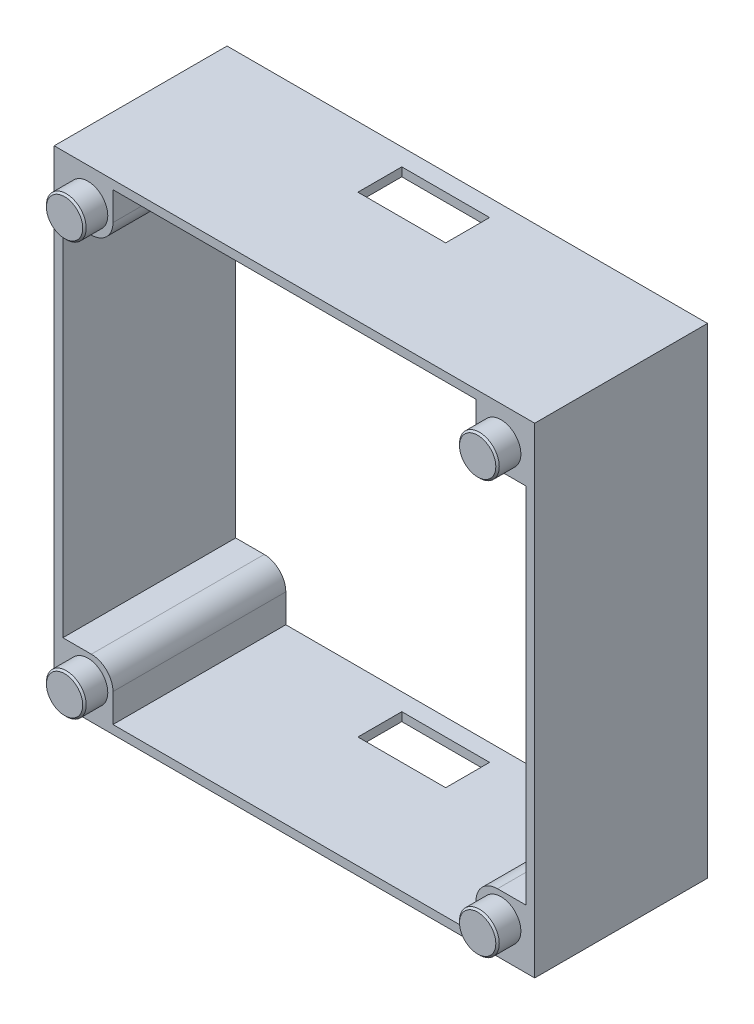
from build123d import *

# Parameters (mm, degrees)
SKICA1_W                 = 5.8
SKICA1_H                 = 5.8
SKICA1_W_2               = 1
SKICA1_H_2               = 42
SKICA1_W_3               = 42
SKICA1_H_3               = 1
P_IDAT_VYSUNUT_M2_DEPTH  = 20
ZAOBLIT1_R               = 2.5
SKICA2_R                 = 2.4
ODEBRAT_VYSUNUT_M1_DEPTH = 1.9
SKICA3_R                 = 2.3
P_IDAT_VYSUNUT_M3_DEPTH  = 2.7
ZKOSEN_1_SIZE            = 0.2
SKICA4_W                 = 10.16
SKICA4_H                 = 5.08
ODEBRAT_VYSUNUT_M2_DEPTH = 68.7


with BuildPart() as part:
    # Skica1 → Přidat vysunutím2 (new body)
    with BuildSketch(Plane.XY):
        Polygon((-27.8, 27.8), (-27.8, 21), (-26.8, 21), (-26.8, 26.8), (-21, 26.8), (-21, 27.8), align=None)
        with Locations((-23.9, 23.9)):
            Rectangle(SKICA1_W, SKICA1_H)
        Polygon((26.8, 21), (27.8, 21), (27.8, 27.8), (21, 27.8), (21, 26.8), (26.8, 26.8), align=None)
        with Locations((23.9, 23.9)):
            Rectangle(SKICA1_W, SKICA1_H)
        Polygon((21, -26.8), (21, -27.8), (27.8, -27.8), (27.8, -21), (26.8, -21), (26.8, -26.8), align=None)
        with Locations((23.9, -23.9)):
            Rectangle(SKICA1_W, SKICA1_H)
        with Locations((-23.9, -23.9)):
            Rectangle(SKICA1_W, SKICA1_H)
        Polygon((-27.8, -27.8), (-21, -27.8), (-21, -26.8), (-26.8, -26.8), (-26.8, -21), (-27.8, -21), align=None)
        with Locations((-27.3, 0)):
            Rectangle(SKICA1_W_2, SKICA1_H_2)
        with Locations((0, -27.3)):
            Rectangle(SKICA1_W_3, SKICA1_H_3)
        with Locations((27.3, 0)):
            Rectangle(SKICA1_W_2, SKICA1_H_2)
        with Locations((0, 27.3)):
            Rectangle(SKICA1_W_3, SKICA1_H_3)
    extrude(amount=P_IDAT_VYSUNUT_M2_DEPTH)

    # Zaoblit1
    zaoblit1_edges = [part.edges().sort_by_distance(p)[0] for p in [
        (21, -21, 10),
        (21, 21, 10),
        (-21, 21, 10),
        (-21, -21, 10),
    ]]
    fillet(zaoblit1_edges, radius=ZAOBLIT1_R)

    # Skica2 → Odebrat vysunutím1 (cut)
    with BuildSketch(Plane(origin=(0, 0, 0), x_dir=(-1, 0, 0), z_dir=(0, 0, -1))):
        with Locations((-23.9, 23.9)):
            Circle(SKICA2_R)
        with Locations((23.9, 23.9)):
            Circle(SKICA2_R)
        with Locations((23.9, -23.9)):
            Circle(SKICA2_R)
        with Locations((-23.9, -23.9)):
            Circle(SKICA2_R)
    extrude(amount=-ODEBRAT_VYSUNUT_M1_DEPTH, mode=Mode.SUBTRACT)

    # Skica3 → Přidat vysunutím3 (add)
    with BuildSketch(Plane.XY.offset(20)):
        with Locations((-23.9, 23.9)):
            Circle(SKICA3_R)
        with Locations((23.9, 23.9)):
            Circle(SKICA3_R)
        with Locations((23.9, -23.9)):
            Circle(SKICA3_R)
        with Locations((-23.9, -23.9)):
            Circle(SKICA3_R)
    extrude(amount=P_IDAT_VYSUNUT_M3_DEPTH)

    # Zkosení1
    zkosen_1_edges = [part.edges().sort_by_distance(p)[0] for p in [
        (-26.2, 23.9, 22.7),
        (21.6, 23.9, 22.7),
        (21.6, -23.9, 22.7),
        (-26.2, -23.9, 22.7),
    ]]
    chamfer(zkosen_1_edges, length=ZKOSEN_1_SIZE)

    # Skica4 → Odebrat vysunutím2 (cut)
    with BuildSketch(Plane(origin=(0, -27.8, 0), x_dir=(-1, 0, 0), z_dir=(0, -1, 0))):
        with Locations((0.5, -4.54)):
            Rectangle(SKICA4_W, SKICA4_H)
    extrude(amount=-ODEBRAT_VYSUNUT_M2_DEPTH, mode=Mode.SUBTRACT)


solid = part.part
